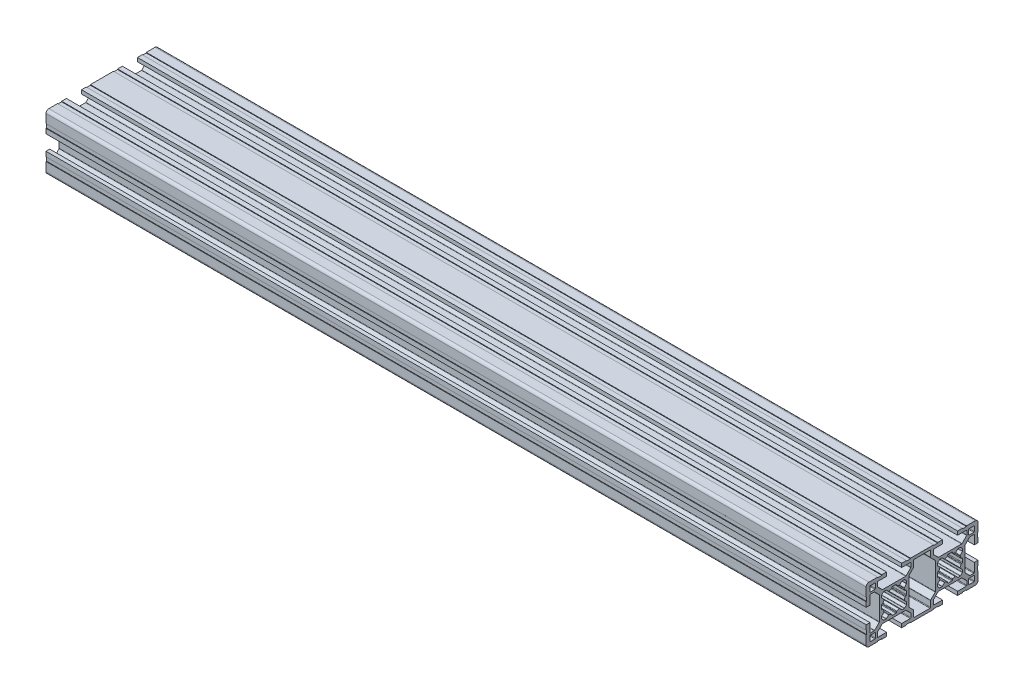
from build123d import *

# Parameters (mm, degrees)
RETANGULAR_PF30_02_PERFIL_3060_B_SICO_DEPTH = 440


with BuildPart() as part:
    # Sketch11 → Retangular PF30-02 - PERFIL 3060 BÁSICO(1) (new body)
    with BuildSketch(Plane.YZ.offset(-220)):
        with BuildLine():
            Line((-10.467761979, 23.914900409), (-7.987862303, 21.435000909))
            ThreePointArc((-7.987862303, 21.435000909), (-7.922830472, 21.337673902), (-7.89999433, 21.222868867))
            Line((-7.89999433, 21.222868867), (-7.89999433, 8.78267257))
            ThreePointArc((-7.89999433, 8.78267257), (-7.922830472, 8.667867535), (-7.987862303, 8.570540528))
            Line((-7.987862303, 8.570540528), (-10.467761979, 6.090641028))
            ThreePointArc((-10.467761979, 6.090641028), (-10.565088981, 6.025609208), (-10.679894006, 6.00277307))
            Line((-10.679894006, 6.00277307), (-12.699995366, 6.00277307))
            ThreePointArc((-12.699995366, 6.00277307), (-12.9121274, 6.090641035), (-12.999995366, 6.30277307))
            Line((-12.999995366, 6.30277307), (-12.999995366, 10.952772018))
            Line((-12.999995366, 10.952772018), (-14.999995923, 10.952772018))
            Line((-14.999995923, 10.952772018), (-14.999995923, 8.402773901))
            Line((-14.999995923, 8.402773901), (-14.699995922, 8.402773901))
            Line((-14.699995922, 8.402773901), (-14.699995922, 6.2027739))
            Line((-14.699995922, 6.2027739), (-14.999995923, 6.2027739))
            Line((-14.999995923, 6.2027739), (-14.999995923, -6.197224309))
            Line((-14.999995923, -6.197224309), (-14.699995922, -6.197224309))
            Line((-14.699995922, -6.197224309), (-14.699995922, -8.397224309))
            Line((-14.699995922, -8.397224309), (-14.999995923, -8.397224309))
            Line((-14.999995923, -8.397224309), (-14.999995923, -10.947222427))
            Line((-14.999995923, -10.947222427), (-12.999995366, -10.947222427))
            Line((-12.999995366, -10.947222427), (-12.999995366, -6.297223478))
            ThreePointArc((-12.999995366, -6.297223478), (-12.9121274, -6.085091444), (-12.699995366, -5.997223478))
            Line((-12.699995366, -5.997223478), (-10.679894006, -5.997223478))
            ThreePointArc((-10.679894006, -5.997223478), (-10.565088981, -6.020059616), (-10.467761979, -6.085091436))
            Line((-10.467761979, -6.085091436), (-7.987862303, -8.564990936))
            ThreePointArc((-7.987862303, -8.564990936), (-7.922830472, -8.662317943), (-7.89999433, -8.777122978))
            Line((-7.89999433, -8.777122978), (-7.89999433, -21.217319276))
            ThreePointArc((-7.89999433, -21.217319276), (-7.922830472, -21.33212431), (-7.987862303, -21.429451318))
            Line((-7.987862303, -21.429451318), (-10.467761979, -23.909350818))
            ThreePointArc((-10.467761979, -23.909350818), (-10.565088981, -23.974382637), (-10.679894006, -23.997218776))
            Line((-10.679894006, -23.997218776), (-12.699995366, -23.997218776))
            ThreePointArc((-12.699995366, -23.997218776), (-12.9121274, -23.90935081), (-12.999995366, -23.697218776))
            Line((-12.999995366, -23.697218776), (-12.999995366, -19.047219827))
            Line((-12.999995366, -19.047219827), (-14.999995923, -19.047219827))
            Line((-14.999995923, -19.047219827), (-14.999995923, -21.597217945))
            Line((-14.999995923, -21.597217945), (-14.699995922, -21.597217945))
            Line((-14.699995922, -21.597217945), (-14.699995922, -23.797217945))
            Line((-14.699995922, -23.797217945), (-14.999995923, -23.797217945))
            Line((-14.999995923, -23.797217945), (-14.999995923, -28.497216952))
            ThreePointArc((-14.999995923, -28.497216952), (-14.560656066, -29.557877193), (-13.499995825, -29.997217049))
            Line((-13.499995825, -29.997217049), (-8.799996802, -29.997217049))
            Line((-8.799996802, -29.997217049), (-8.799996802, -29.697217049))
            Line((-8.799996802, -29.697217049), (-6.599996802, -29.697217049))
            Line((-6.599996802, -29.697217049), (-6.599996802, -29.99721705))
            Line((-6.599996802, -29.99721705), (-4.0499987, -29.99721705))
            Line((-4.0499987, -29.99721705), (-4.0499987, -27.997216493))
            Line((-4.0499987, -27.997216493), (-8.699997649, -27.997216493))
            ThreePointArc((-8.699997649, -27.997216493), (-8.912129683, -27.909348527), (-8.999997649, -27.697216493))
            Line((-8.999997649, -27.697216493), (-8.999997649, -25.677115133))
            ThreePointArc((-8.999997649, -25.677115133), (-8.977161511, -25.562310108), (-8.912129691, -25.464983106))
            Line((-8.912129691, -25.464983106), (-6.432230191, -22.98508343))
            ThreePointArc((-6.432230191, -22.98508343), (-6.334903184, -22.920051599), (-6.220098149, -22.897215457))
            Line((-6.220098149, -22.897215457), (6.220098149, -22.897215457))
            ThreePointArc((6.220098149, -22.897215457), (6.334903184, -22.920051599), (6.432230191, -22.98508343))
            Line((6.432230191, -22.98508343), (8.912129691, -25.464983106))
            ThreePointArc((8.912129691, -25.464983106), (8.977161511, -25.562310108), (8.999997649, -25.677115133))
            Line((8.999997649, -25.677115133), (8.999997649, -27.697216493))
            ThreePointArc((8.999997649, -27.697216493), (8.912129683, -27.909348527), (8.699997649, -27.997216493))
            Line((8.699997649, -27.997216493), (4.0499987, -27.997216493))
            Line((4.0499987, -27.997216493), (4.0499987, -29.99721705))
            Line((4.0499987, -29.99721705), (6.599996802, -29.99721705))
            Line((6.599996802, -29.99721705), (6.599996802, -29.697217049))
            Line((6.599996802, -29.697217049), (8.799996802, -29.697217049))
            Line((8.799996802, -29.697217049), (8.799996802, -29.997217049))
            Line((8.799996802, -29.997217049), (13.499995825, -29.997217049))
            ThreePointArc((13.499995825, -29.997217049), (14.560656066, -29.557877193), (14.999995923, -28.497216952))
            Line((14.999995923, -28.497216952), (14.999995923, -23.797217945))
            Line((14.999995923, -23.797217945), (14.699995922, -23.797217945))
            Line((14.699995922, -23.797217945), (14.699995922, -21.597217945))
            Line((14.699995922, -21.597217945), (14.999995923, -21.597217945))
            Line((14.999995923, -21.597217945), (14.999995923, -19.047219827))
            Line((14.999995923, -19.047219827), (12.999995366, -19.047219827))
            Line((12.999995366, -19.047219827), (12.999995366, -23.697218776))
            ThreePointArc((12.999995366, -23.697218776), (12.9121274, -23.90935081), (12.699995366, -23.997218776))
            Line((12.699995366, -23.997218776), (10.679894006, -23.997218776))
            ThreePointArc((10.679894006, -23.997218776), (10.565088981, -23.974382637), (10.467761979, -23.909350818))
            Line((10.467761979, -23.909350818), (7.987862303, -21.429451318))
            ThreePointArc((7.987862303, -21.429451318), (7.922830472, -21.33212431), (7.89999433, -21.217319276))
            Line((7.89999433, -21.217319276), (7.89999433, -8.777122978))
            ThreePointArc((7.89999433, -8.777122978), (7.922830472, -8.662317943), (7.987862303, -8.564990936))
            Line((7.987862303, -8.564990936), (10.467761979, -6.085091436))
            ThreePointArc((10.467761979, -6.085091436), (10.565088981, -6.020059616), (10.679894006, -5.997223478))
            Line((10.679894006, -5.997223478), (12.699995366, -5.997223478))
            ThreePointArc((12.699995366, -5.997223478), (12.9121274, -6.085091444), (12.999995366, -6.297223478))
            Line((12.999995366, -6.297223478), (12.999995366, -10.947222427))
            Line((12.999995366, -10.947222427), (14.999995923, -10.947222427))
            Line((14.999995923, -10.947222427), (14.999995923, -8.397224309))
            Line((14.999995923, -8.397224309), (14.699995922, -8.397224309))
            Line((14.699995922, -8.397224309), (14.699995922, -6.197224309))
            Line((14.699995922, -6.197224309), (14.999995923, -6.197224309))
            Line((14.999995923, -6.197224309), (14.999995923, 6.2027739))
            Line((14.999995923, 6.2027739), (14.699995922, 6.2027739))
            Line((14.699995922, 6.2027739), (14.699995922, 8.402773901))
            Line((14.699995922, 8.402773901), (14.999995923, 8.402773901))
            Line((14.999995923, 8.402773901), (14.999995923, 10.952772018))
            Line((14.999995923, 10.952772018), (12.999995366, 10.952772018))
            Line((12.999995366, 10.952772018), (12.999995366, 6.30277307))
            ThreePointArc((12.999995366, 6.30277307), (12.9121274, 6.090641035), (12.699995366, 6.00277307))
            Line((12.699995366, 6.00277307), (10.679894006, 6.00277307))
            ThreePointArc((10.679894006, 6.00277307), (10.565088981, 6.025609208), (10.467761979, 6.090641028))
            Line((10.467761979, 6.090641028), (7.987862303, 8.570540528))
            ThreePointArc((7.987862303, 8.570540528), (7.922830472, 8.667867535), (7.89999433, 8.78267257))
            Line((7.89999433, 8.78267257), (7.89999433, 21.222868867))
            ThreePointArc((7.89999433, 21.222868867), (7.922830472, 21.337673902), (7.987862303, 21.435000909))
            Line((7.987862303, 21.435000909), (10.467761979, 23.914900409))
            ThreePointArc((10.467761979, 23.914900409), (10.565088981, 23.979932229), (10.679894006, 24.002768367))
            Line((10.679894006, 24.002768367), (12.699995366, 24.002768367))
            ThreePointArc((12.699995366, 24.002768367), (12.9121274, 23.914900401), (12.999995366, 23.702768367))
            Line((12.999995366, 23.702768367), (12.999995366, 19.052769418))
            Line((12.999995366, 19.052769418), (14.999995923, 19.052769418))
            Line((14.999995923, 19.052769418), (14.999995923, 21.602767536))
            Line((14.999995923, 21.602767536), (14.699995922, 21.602767536))
            Line((14.699995922, 21.602767536), (14.699995922, 23.802767536))
            Line((14.699995922, 23.802767536), (14.999995923, 23.802767536))
            Line((14.999995923, 23.802767536), (14.999995923, 28.502766544))
            ThreePointArc((14.999995923, 28.502766544), (14.560656066, 29.563426784), (13.499995825, 30.002766641))
            Line((13.499995825, 30.002766641), (8.799996802, 30.002766641))
            Line((8.799996802, 30.002766641), (8.799996802, 29.702766641))
            Line((8.799996802, 29.702766641), (6.599996802, 29.702766641))
            Line((6.599996802, 29.702766641), (6.599996802, 30.002766641))
            Line((6.599996802, 30.002766641), (4.0499987, 30.002766641))
            Line((4.0499987, 30.002766641), (4.0499987, 28.002766084))
            Line((4.0499987, 28.002766084), (8.699997649, 28.002766084))
            ThreePointArc((8.699997649, 28.002766084), (8.912129683, 27.914898119), (8.999997649, 27.702766084))
            Line((8.999997649, 27.702766084), (8.999997649, 25.682664725))
            ThreePointArc((8.999997649, 25.682664725), (8.977161511, 25.5678597), (8.912129691, 25.470532698))
            Line((8.912129691, 25.470532698), (6.432230191, 22.990633021))
            ThreePointArc((6.432230191, 22.990633021), (6.334903184, 22.92560119), (6.220098149, 22.902765048))
            Line((6.220098149, 22.902765048), (-6.220098149, 22.902765048))
            ThreePointArc((-6.220098149, 22.902765048), (-6.334903184, 22.92560119), (-6.432230191, 22.990633021))
            Line((-6.432230191, 22.990633021), (-8.912129691, 25.470532698))
            ThreePointArc((-8.912129691, 25.470532698), (-8.977161511, 25.5678597), (-8.999997649, 25.682664725))
            Line((-8.999997649, 25.682664725), (-8.999997649, 27.702766084))
            ThreePointArc((-8.999997649, 27.702766084), (-8.912129683, 27.914898119), (-8.699997649, 28.002766084))
            Line((-8.699997649, 28.002766084), (-4.0499987, 28.002766084))
            Line((-4.0499987, 28.002766084), (-4.0499987, 30.002766641))
            Line((-4.0499987, 30.002766641), (-6.599996802, 30.002766641))
            Line((-6.599996802, 30.002766641), (-6.599996802, 29.702766641))
            Line((-6.599996802, 29.702766641), (-8.799996802, 29.702766641))
            Line((-8.799996802, 29.702766641), (-8.799996802, 30.002766641))
            Line((-8.799996802, 30.002766641), (-13.499995825, 30.002766641))
            ThreePointArc((-13.499995825, 30.002766641), (-14.560656066, 29.563426784), (-14.999995923, 28.502766544))
            Line((-14.999995923, 28.502766544), (-14.999995923, 23.802767536))
            Line((-14.999995923, 23.802767536), (-14.699995922, 23.802767536))
            Line((-14.699995922, 23.802767536), (-14.699995922, 21.602767536))
            Line((-14.699995922, 21.602767536), (-14.999995923, 21.602767536))
            Line((-14.999995923, 21.602767536), (-14.999995923, 19.052769418))
            Line((-14.999995923, 19.052769418), (-12.999995366, 19.052769418))
            Line((-12.999995366, 19.052769418), (-12.999995366, 23.702768367))
            ThreePointArc((-12.999995366, 23.702768367), (-12.9121274, 23.914900401), (-12.699995366, 24.002768367))
            Line((-12.699995366, 24.002768367), (-10.679894006, 24.002768367))
            ThreePointArc((-10.679894006, 24.002768367), (-10.565088981, 23.979932229), (-10.467761979, 23.914900409))
        make_face()
        with BuildLine():
            Line((-9.846446918, -4.590642769), (-7.422182, -7.014907859))
            ThreePointArc((-7.422182, -7.014907859), (-7.324854993, -7.07993969), (-7.210049959, -7.102775832))
            Line((-7.210049959, -7.102775832), (7.210049959, -7.102775832))
            ThreePointArc((7.210049959, -7.102775832), (7.324854993, -7.07993969), (7.422182, -7.014907859))
            Line((7.422182, -7.014907859), (9.846446918, -4.590642769))
            ThreePointArc((9.846446918, -4.590642769), (9.943773925, -4.525610938), (10.05857896, -4.502774796))
            Line((10.05857896, -4.502774796), (13.2, -4.502774796))
            ThreePointArc((13.2, -4.502774796), (13.412132034, -4.41490683), (13.5, -4.202774796))
            Line((13.5, -4.202774796), (13.5, 4.197225204))
            ThreePointArc((13.5, 4.197225204), (13.412132034, 4.409357239), (13.2, 4.497225204))
            Line((13.2, 4.497225204), (10.05857896, 4.497225204))
            ThreePointArc((10.05857896, 4.497225204), (9.943773925, 4.520061347), (9.846446918, 4.585093178))
            Line((9.846446918, 4.585093178), (7.422182001, 7.009358267))
            ThreePointArc((7.422182001, 7.009358267), (7.324854993, 7.074390098), (7.210049959, 7.097226241))
            Line((7.210049959, 7.097226241), (-7.210049958, 7.097226241))
            ThreePointArc((-7.210049958, 7.097226241), (-7.324854993, 7.074390098), (-7.422182, 7.009358267))
            Line((-7.422182, 7.009358267), (-9.846446917, 4.585093178))
            ThreePointArc((-9.846446917, 4.585093178), (-9.943773925, 4.520061347), (-10.058578959, 4.497225204))
            Line((-10.058578959, 4.497225204), (-13.2, 4.497225204))
            ThreePointArc((-13.2, 4.497225204), (-13.412132034, 4.409357239), (-13.5, 4.197225204))
            Line((-13.5, 4.197225204), (-13.5, -4.202774796))
            ThreePointArc((-13.5, -4.202774796), (-13.412132034, -4.41490683), (-13.2, -4.502774796))
            Line((-13.2, -4.502774796), (-10.05857896, -4.502774796))
            ThreePointArc((-10.05857896, -4.502774796), (-9.943773925, -4.525610938), (-9.846446918, -4.590642769))
        make_face(mode=Mode.SUBTRACT)
        with BuildLine():
            Line((-6.69999433, 15.952769357), (-6.69999433, 14.05277208))
            ThreePointArc((-6.69999433, 14.05277208), (-6.612125883, 13.840639564), (-6.399992969, 13.75277208))
            Line((-6.399992969, 13.75277208), (-6.157923707, 13.752773178))
            ThreePointArc((-6.157923707, 13.752773178), (-5.973489249, 13.689383475), (-5.866996881, 13.526001408))
            ThreePointArc((-5.866996881, 13.526001408), (-5.679815238, 12.918976375), (-5.430017698, 12.334923683))
            ThreePointArc((-5.430017698, 12.334923683), (-5.403317864, 12.15354701), (-5.487142739, 11.990501713))
            Line((-5.487142739, 11.990501713), (-6.612126364, 10.865518089))
            ThreePointArc((-6.612126364, 10.865518089), (-6.677158189, 10.768191084), (-6.69999433, 10.653386054))
            Line((-6.69999433, 10.653386054), (-6.69999433, 9.563210784))
            ThreePointArc((-6.69999433, 9.563210784), (-6.677158176, 9.448405723), (-6.612126315, 9.351078701))
            Line((-6.612126315, 9.351078701), (-6.131909052, 8.870861658))
            Line((-6.131909052, 8.870861658), (-5.651692017, 8.390644403))
            ThreePointArc((-5.651692017, 8.390644403), (-5.554364996, 8.325612542), (-5.439559934, 8.302776389))
            Line((-5.439559934, 8.302776389), (-4.349384664, 8.302776389))
            ThreePointArc((-4.349384664, 8.302776389), (-4.234579634, 8.325612529), (-4.13725263, 8.390644354))
            Line((-4.13725263, 8.390644354), (-3.012269005, 9.515627979))
            ThreePointArc((-3.012269005, 9.515627979), (-2.849223708, 9.599452854), (-2.667847035, 9.572753021))
            ThreePointArc((-2.667847035, 9.572753021), (-2.083794343, 9.322955481), (-1.476769311, 9.135773837))
            ThreePointArc((-1.476769311, 9.135773837), (-1.313387244, 9.02928147), (-1.249997541, 8.844847011))
            Line((-1.249997541, 8.844847011), (-1.249998639, 8.60277775))
            ThreePointArc((-1.249998639, 8.60277775), (-1.162131155, 8.390644836), (-0.949998639, 8.302776389))
            Line((-0.949998639, 8.302776389), (0.949998639, 8.302776389))
            ThreePointArc((0.949998639, 8.302776389), (1.162131155, 8.390644836), (1.249998639, 8.60277775))
            Line((1.249998639, 8.60277775), (1.249997541, 8.844847011))
            ThreePointArc((1.249997541, 8.844847011), (1.313387244, 9.02928147), (1.476769311, 9.135773837))
            ThreePointArc((1.476769311, 9.135773837), (2.083794343, 9.322955481), (2.667847035, 9.572753021))
            ThreePointArc((2.667847035, 9.572753021), (2.849223708, 9.599452854), (3.012269005, 9.515627979))
            Line((3.012269005, 9.515627979), (4.13725263, 8.390644354))
            ThreePointArc((4.13725263, 8.390644354), (4.234579634, 8.325612529), (4.349384664, 8.302776389))
            Line((4.349384664, 8.302776389), (5.439559934, 8.302776389))
            ThreePointArc((5.439559934, 8.302776389), (5.554364996, 8.325612542), (5.651692017, 8.390644403))
            Line((5.651692017, 8.390644403), (6.131909052, 8.870861658))
            Line((6.131909052, 8.870861658), (6.612126315, 9.351078701))
            ThreePointArc((6.612126315, 9.351078701), (6.677158176, 9.448405723), (6.69999433, 9.563210784))
            Line((6.69999433, 9.563210784), (6.69999433, 10.653386054))
            ThreePointArc((6.69999433, 10.653386054), (6.677158189, 10.768191084), (6.612126364, 10.865518089))
            Line((6.612126364, 10.865518089), (5.487142739, 11.990501713))
            ThreePointArc((5.487142739, 11.990501713), (5.403317864, 12.15354701), (5.430017698, 12.334923683))
            ThreePointArc((5.430017698, 12.334923683), (5.679815238, 12.918976375), (5.866996881, 13.526001408))
            ThreePointArc((5.866996881, 13.526001408), (5.973489249, 13.689383475), (6.157923707, 13.752773178))
            Line((6.157923707, 13.752773178), (6.399992969, 13.75277208))
            ThreePointArc((6.399992969, 13.75277208), (6.612125883, 13.840639564), (6.69999433, 14.05277208))
            Line((6.69999433, 14.05277208), (6.69999433, 15.952769357))
            ThreePointArc((6.69999433, 15.952769357), (6.612125883, 16.164901872), (6.399992969, 16.252769357))
            Line((6.399992969, 16.252769357), (6.157923707, 16.252768259))
            ThreePointArc((6.157923707, 16.252768259), (5.973489249, 16.316157962), (5.866996881, 16.479540029))
            ThreePointArc((5.866996881, 16.479540029), (5.679815238, 17.086565061), (5.430017698, 17.670617753))
            ThreePointArc((5.430017698, 17.670617753), (5.403317864, 17.851994426), (5.487142739, 18.015039723))
            Line((5.487142739, 18.015039723), (6.612126364, 19.140023348))
            ThreePointArc((6.612126364, 19.140023348), (6.677158189, 19.237350353), (6.69999433, 19.352155382))
            Line((6.69999433, 19.352155382), (6.69999433, 20.442330653))
            ThreePointArc((6.69999433, 20.442330653), (6.677158176, 20.557135714), (6.612126315, 20.654462736))
            Line((6.612126315, 20.654462736), (6.131909052, 21.134679779))
            Line((6.131909052, 21.134679779), (5.651692017, 21.614897034))
            ThreePointArc((5.651692017, 21.614897034), (5.554364996, 21.679928895), (5.439559934, 21.702765048))
            Line((5.439559934, 21.702765048), (4.349384664, 21.702765048))
            ThreePointArc((4.349384664, 21.702765048), (4.234579634, 21.679928908), (4.13725263, 21.614897082))
            Line((4.13725263, 21.614897082), (3.012269005, 20.489913458))
            ThreePointArc((3.012269005, 20.489913458), (2.849223708, 20.406088583), (2.667847035, 20.432788416))
            ThreePointArc((2.667847035, 20.432788416), (2.083794343, 20.682585956), (1.476769311, 20.869767599))
            ThreePointArc((1.476769311, 20.869767599), (1.313387244, 20.976259967), (1.249997541, 21.160694426))
            Line((1.249997541, 21.160694426), (1.249998639, 21.402763687))
            ThreePointArc((1.249998639, 21.402763687), (1.162131155, 21.614896601), (0.949998639, 21.702765048))
            Line((0.949998639, 21.702765048), (-0.949998639, 21.702765048))
            ThreePointArc((-0.949998639, 21.702765048), (-1.162131155, 21.614896601), (-1.249998639, 21.402763687))
            Line((-1.249998639, 21.402763687), (-1.249997541, 21.160694426))
            ThreePointArc((-1.249997541, 21.160694426), (-1.313387244, 20.976259967), (-1.476769311, 20.869767599))
            ThreePointArc((-1.476769311, 20.869767599), (-2.083794343, 20.682585956), (-2.667847035, 20.432788416))
            ThreePointArc((-2.667847035, 20.432788416), (-2.849223708, 20.406088583), (-3.012269005, 20.489913458))
            Line((-3.012269005, 20.489913458), (-4.13725263, 21.614897082))
            ThreePointArc((-4.13725263, 21.614897082), (-4.234579634, 21.679928908), (-4.349384664, 21.702765048))
            Line((-4.349384664, 21.702765048), (-5.439559934, 21.702765048))
            ThreePointArc((-5.439559934, 21.702765048), (-5.554364996, 21.679928895), (-5.651692017, 21.614897034))
            Line((-5.651692017, 21.614897034), (-6.131909052, 21.134679779))
            Line((-6.131909052, 21.134679779), (-6.612126315, 20.654462736))
            ThreePointArc((-6.612126315, 20.654462736), (-6.677158176, 20.557135714), (-6.69999433, 20.442330653))
            Line((-6.69999433, 20.442330653), (-6.69999433, 19.352155382))
            ThreePointArc((-6.69999433, 19.352155382), (-6.677158189, 19.237350353), (-6.612126364, 19.140023348))
            Line((-6.612126364, 19.140023348), (-5.487142739, 18.015039723))
            ThreePointArc((-5.487142739, 18.015039723), (-5.403317864, 17.851994426), (-5.430017698, 17.670617753))
            ThreePointArc((-5.430017698, 17.670617753), (-5.679815238, 17.086565061), (-5.866996881, 16.479540029))
            ThreePointArc((-5.866996881, 16.479540029), (-5.973489249, 16.316157962), (-6.157923707, 16.252768259))
            Line((-6.157923707, 16.252768259), (-6.399992969, 16.252769357))
            ThreePointArc((-6.399992969, 16.252769357), (-6.612125883, 16.164901872), (-6.69999433, 15.952769357))
        make_face(mode=Mode.SUBTRACT)
        with BuildLine():
            Line((-12.999997649, 25.302766084), (-12.999997649, 27.702766084))
            ThreePointArc((-12.999997649, 27.702766084), (-12.912129683, 27.914898119), (-12.699997649, 28.002766084))
            Line((-12.699997649, 28.002766084), (-10.299997649, 28.002766084))
            ThreePointArc((-10.299997649, 28.002766084), (-10.087865615, 27.914898119), (-9.999997649, 27.702766084))
            Line((-9.999997649, 27.702766084), (-9.999997649, 25.302766084))
            ThreePointArc((-9.999997649, 25.302766084), (-10.087865615, 25.09063405), (-10.299997649, 25.002766084))
            Line((-10.299997649, 25.002766084), (-12.699997649, 25.002766084))
            ThreePointArc((-12.699997649, 25.002766084), (-12.912129683, 25.09063405), (-12.999997649, 25.302766084))
        make_face(mode=Mode.SUBTRACT)
        with BuildLine():
            Line((10.299997649, 25.002766084), (12.699997649, 25.002766084))
            ThreePointArc((12.699997649, 25.002766084), (12.912129683, 25.09063405), (12.999997649, 25.302766084))
            Line((12.999997649, 25.302766084), (12.999997649, 27.702766084))
            ThreePointArc((12.999997649, 27.702766084), (12.912129683, 27.914898119), (12.699997649, 28.002766084))
            Line((12.699997649, 28.002766084), (10.299997649, 28.002766084))
            ThreePointArc((10.299997649, 28.002766084), (10.087865615, 27.914898119), (9.999997649, 27.702766084))
            Line((9.999997649, 27.702766084), (9.999997649, 25.302766084))
            ThreePointArc((9.999997649, 25.302766084), (10.087865615, 25.09063405), (10.299997649, 25.002766084))
        make_face(mode=Mode.SUBTRACT)
        with BuildLine():
            Line((-6.157923707, -13.747223586), (-6.399992969, -13.747222488))
            ThreePointArc((-6.399992969, -13.747222488), (-6.612125883, -13.835089973), (-6.69999433, -14.047222488))
            Line((-6.69999433, -14.047222488), (-6.69999433, -15.947219765))
            ThreePointArc((-6.69999433, -15.947219765), (-6.612125883, -16.159352281), (-6.399992969, -16.247219765))
            Line((-6.399992969, -16.247219765), (-6.157923707, -16.247218667))
            ThreePointArc((-6.157923707, -16.247218667), (-5.973489249, -16.310608371), (-5.866996881, -16.473990437))
            ThreePointArc((-5.866996881, -16.473990437), (-5.679815238, -17.08101547), (-5.430017698, -17.665068162))
            ThreePointArc((-5.430017698, -17.665068162), (-5.403317864, -17.846444835), (-5.487142739, -18.009490132))
            Line((-5.487142739, -18.009490132), (-6.612126364, -19.134473757))
            ThreePointArc((-6.612126364, -19.134473757), (-6.677158189, -19.231800761), (-6.69999433, -19.346605791))
            Line((-6.69999433, -19.346605791), (-6.69999433, -20.436781061))
            ThreePointArc((-6.69999433, -20.436781061), (-6.677158176, -20.551586123), (-6.612126315, -20.648913144))
            Line((-6.612126315, -20.648913144), (-6.131909052, -21.129130187))
            Line((-6.131909052, -21.129130187), (-5.651692017, -21.609347442))
            ThreePointArc((-5.651692017, -21.609347442), (-5.554364996, -21.674379303), (-5.439559934, -21.697215457))
            Line((-5.439559934, -21.697215457), (-4.349384664, -21.697215457))
            ThreePointArc((-4.349384664, -21.697215457), (-4.234579634, -21.674379316), (-4.13725263, -21.609347491))
            Line((-4.13725263, -21.609347491), (-3.012269005, -20.484363866))
            ThreePointArc((-3.012269005, -20.484363866), (-2.849223708, -20.400538991), (-2.667847035, -20.427238825))
            ThreePointArc((-2.667847035, -20.427238825), (-2.083794343, -20.677036365), (-1.476769311, -20.864218008))
            ThreePointArc((-1.476769311, -20.864218008), (-1.313387244, -20.970710376), (-1.249997541, -21.155144834))
            Line((-1.249997541, -21.155144834), (-1.249998639, -21.397214096))
            ThreePointArc((-1.249998639, -21.397214096), (-1.162131155, -21.60934701), (-0.949998639, -21.697215457))
            Line((-0.949998639, -21.697215457), (0.949998639, -21.697215457))
            ThreePointArc((0.949998639, -21.697215457), (1.162131155, -21.60934701), (1.249998639, -21.397214096))
            Line((1.249998639, -21.397214096), (1.249997541, -21.155144834))
            ThreePointArc((1.249997541, -21.155144834), (1.313387244, -20.970710376), (1.476769311, -20.864218008))
            ThreePointArc((1.476769311, -20.864218008), (2.083794343, -20.677036365), (2.667847035, -20.427238825))
            ThreePointArc((2.667847035, -20.427238825), (2.849223708, -20.400538991), (3.012269005, -20.484363866))
            Line((3.012269005, -20.484363866), (4.13725263, -21.609347491))
            ThreePointArc((4.13725263, -21.609347491), (4.234579634, -21.674379316), (4.349384664, -21.697215457))
            Line((4.349384664, -21.697215457), (5.439559934, -21.697215457))
            ThreePointArc((5.439559934, -21.697215457), (5.554364996, -21.674379303), (5.651692017, -21.609347442))
            Line((5.651692017, -21.609347442), (6.131909052, -21.129130187))
            Line((6.131909052, -21.129130187), (6.612126315, -20.648913144))
            ThreePointArc((6.612126315, -20.648913144), (6.677158176, -20.551586123), (6.69999433, -20.436781061))
            Line((6.69999433, -20.436781061), (6.69999433, -19.346605791))
            ThreePointArc((6.69999433, -19.346605791), (6.677158189, -19.231800761), (6.612126364, -19.134473757))
            Line((6.612126364, -19.134473757), (5.487142739, -18.009490132))
            ThreePointArc((5.487142739, -18.009490132), (5.403317864, -17.846444835), (5.430017698, -17.665068162))
            ThreePointArc((5.430017698, -17.665068162), (5.679815238, -17.08101547), (5.866996881, -16.473990437))
            ThreePointArc((5.866996881, -16.473990437), (5.973489249, -16.310608371), (6.157923707, -16.247218667))
            Line((6.157923707, -16.247218667), (6.399992969, -16.247219765))
            ThreePointArc((6.399992969, -16.247219765), (6.612125883, -16.159352281), (6.69999433, -15.947219765))
            Line((6.69999433, -15.947219765), (6.69999433, -14.047222488))
            ThreePointArc((6.69999433, -14.047222488), (6.612125883, -13.835089973), (6.399992969, -13.747222488))
            Line((6.399992969, -13.747222488), (6.157923707, -13.747223586))
            ThreePointArc((6.157923707, -13.747223586), (5.973489249, -13.683833883), (5.866996881, -13.520451817))
            ThreePointArc((5.866996881, -13.520451817), (5.679815238, -12.913426784), (5.430017698, -12.329374092))
            ThreePointArc((5.430017698, -12.329374092), (5.403317864, -12.147997419), (5.487142739, -11.984952122))
            Line((5.487142739, -11.984952122), (6.612126364, -10.859968497))
            ThreePointArc((6.612126364, -10.859968497), (6.677158189, -10.762641493), (6.69999433, -10.647836463))
            Line((6.69999433, -10.647836463), (6.69999433, -9.557661193))
            ThreePointArc((6.69999433, -9.557661193), (6.677158176, -9.442856131), (6.612126315, -9.34552911))
            Line((6.612126315, -9.34552911), (6.131909052, -8.865312067))
            Line((6.131909052, -8.865312067), (5.651692017, -8.385094811))
            ThreePointArc((5.651692017, -8.385094811), (5.554364996, -8.320062951), (5.439559934, -8.297226797))
            Line((5.439559934, -8.297226797), (4.349384664, -8.297226797))
            ThreePointArc((4.349384664, -8.297226797), (4.234579634, -8.320062937), (4.13725263, -8.385094763))
            Line((4.13725263, -8.385094763), (3.012269005, -9.510078388))
            ThreePointArc((3.012269005, -9.510078388), (2.849223708, -9.593903263), (2.667847035, -9.567203429))
            ThreePointArc((2.667847035, -9.567203429), (2.083794343, -9.317405889), (1.476769311, -9.130224246))
            ThreePointArc((1.476769311, -9.130224246), (1.313387244, -9.023731878), (1.249997541, -8.83929742))
            Line((1.249997541, -8.83929742), (1.249998639, -8.597228158))
            ThreePointArc((1.249998639, -8.597228158), (1.162131155, -8.385095244), (0.949998639, -8.297226797))
            Line((0.949998639, -8.297226797), (-0.949998639, -8.297226797))
            ThreePointArc((-0.949998639, -8.297226797), (-1.162131155, -8.385095244), (-1.249998639, -8.597228158))
            Line((-1.249998639, -8.597228158), (-1.249997541, -8.83929742))
            ThreePointArc((-1.249997541, -8.83929742), (-1.313387244, -9.023731878), (-1.476769311, -9.130224246))
            ThreePointArc((-1.476769311, -9.130224246), (-2.083794343, -9.317405889), (-2.667847035, -9.567203429))
            ThreePointArc((-2.667847035, -9.567203429), (-2.849223708, -9.593903263), (-3.012269005, -9.510078388))
            Line((-3.012269005, -9.510078388), (-4.13725263, -8.385094763))
            ThreePointArc((-4.13725263, -8.385094763), (-4.234579634, -8.320062937), (-4.349384664, -8.297226797))
            Line((-4.349384664, -8.297226797), (-5.439559934, -8.297226797))
            ThreePointArc((-5.439559934, -8.297226797), (-5.554364996, -8.320062951), (-5.651692017, -8.385094811))
            Line((-5.651692017, -8.385094811), (-6.131909052, -8.865312067))
            Line((-6.131909052, -8.865312067), (-6.612126315, -9.34552911))
            ThreePointArc((-6.612126315, -9.34552911), (-6.677158176, -9.442856131), (-6.69999433, -9.557661193))
            Line((-6.69999433, -9.557661193), (-6.69999433, -10.647836463))
            ThreePointArc((-6.69999433, -10.647836463), (-6.677158189, -10.762641493), (-6.612126364, -10.859968497))
            Line((-6.612126364, -10.859968497), (-5.487142739, -11.984952122))
            ThreePointArc((-5.487142739, -11.984952122), (-5.403317864, -12.147997419), (-5.430017698, -12.329374092))
            ThreePointArc((-5.430017698, -12.329374092), (-5.679815238, -12.913426784), (-5.866996881, -13.520451817))
            ThreePointArc((-5.866996881, -13.520451817), (-5.973489249, -13.683833883), (-6.157923707, -13.747223586))
        make_face(mode=Mode.SUBTRACT)
        with BuildLine():
            Line((-10.299997649, -24.997216493), (-12.699997649, -24.997216493))
            ThreePointArc((-12.699997649, -24.997216493), (-12.912129683, -25.085084458), (-12.999997649, -25.297216493))
            Line((-12.999997649, -25.297216493), (-12.999997649, -27.697216493))
            ThreePointArc((-12.999997649, -27.697216493), (-12.912129683, -27.909348527), (-12.699997649, -27.997216493))
            Line((-12.699997649, -27.997216493), (-10.299997649, -27.997216493))
            ThreePointArc((-10.299997649, -27.997216493), (-10.087865615, -27.909348527), (-9.999997649, -27.697216493))
            Line((-9.999997649, -27.697216493), (-9.999997649, -25.297216493))
            ThreePointArc((-9.999997649, -25.297216493), (-10.087865615, -25.085084458), (-10.299997649, -24.997216493))
        make_face(mode=Mode.SUBTRACT)
        with BuildLine():
            Line((12.999997649, -25.297216493), (12.999997649, -27.697216493))
            ThreePointArc((12.999997649, -27.697216493), (12.912129683, -27.909348527), (12.699997649, -27.997216493))
            Line((12.699997649, -27.997216493), (10.299997649, -27.997216493))
            ThreePointArc((10.299997649, -27.997216493), (10.087865615, -27.909348527), (9.999997649, -27.697216493))
            Line((9.999997649, -27.697216493), (9.999997649, -25.297216493))
            ThreePointArc((9.999997649, -25.297216493), (10.087865615, -25.085084458), (10.299997649, -24.997216493))
            Line((10.299997649, -24.997216493), (12.699997649, -24.997216493))
            ThreePointArc((12.699997649, -24.997216493), (12.912129683, -25.085084458), (12.999997649, -25.297216493))
        make_face(mode=Mode.SUBTRACT)
    extrude(amount=RETANGULAR_PF30_02_PERFIL_3060_B_SICO_DEPTH)


solid = part.part
